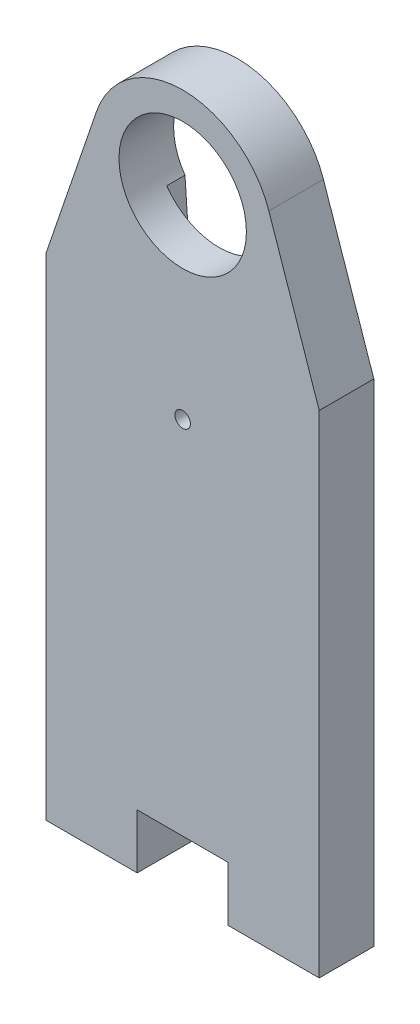
from build123d import *

# Parameters (mm, degrees)
CORTE_EXTERIOR_R        = 0.425
CORTE_EXTERIOR_R_2      = 3.500002336
SALIENTE_EXTRUIR1_DEPTH = 3
CORTAR_EXTRUIR1_DEPTH   = 1


with BuildPart() as part:
    # Corte exterior → Saliente-Extruir1 (new body)
    with BuildSketch(Plane.XY):
        with BuildLine():
            Line((40.01577693, -3.310783785), (40.01577693, 10.689216215))
            Line((40.01577693, 10.689216215), (40.01577693, 23.689216215))
            Line((40.01577693, 23.689216215), (37.248055694, 31.80338402))
            ThreePointArc((37.248055694, 31.80338402), (32.51577693, 35.189216215), (27.783498166, 31.80338402))
            Line((27.783498166, 31.80338402), (25.01577693, 23.689216215))
            Line((25.01577693, 23.689216215), (25.01577693, -3.310783785))
            Line((25.01577693, -3.310783785), (30.01577693, -3.310783785))
            Line((30.01577693, -3.310783785), (30.01577693, -0.310783785))
            Line((30.01577693, -0.310783785), (35.01577693, -0.310783785))
            Line((35.01577693, -0.310783785), (35.01577693, -3.310783785))
            Line((35.01577693, -3.310783785), (40.01577693, -3.310783785))
        make_face()
        with Locations((32.51577693, 19.516986762)):
            Circle(CORTE_EXTERIOR_R, mode=Mode.SUBTRACT)
        with Locations((32.51577693, 30.189216215)):
            Circle(CORTE_EXTERIOR_R_2, mode=Mode.SUBTRACT)
    extrude(amount=SALIENTE_EXTRUIR1_DEPTH)

    # Grabado Superficie → Cortar-Extruir1 (cut)
    with BuildSketch(Plane.XY):
        with BuildLine():
            Line((30.520602357, 15.55036945), (29.64077693, 28.193122191))
            ThreePointArc((29.64077693, 28.193122191), (32.51577693, 26.689213879), (35.39077693, 28.193122191))
            Line((35.39077693, 28.193122191), (34.510951503, 15.55036945))
            ThreePointArc((34.510951503, 15.55036945), (32.51577693, 13.689216215), (30.520602357, 15.55036945))
        make_face()
    extrude(amount=CORTAR_EXTRUIR1_DEPTH, mode=Mode.SUBTRACT)


solid = part.part
